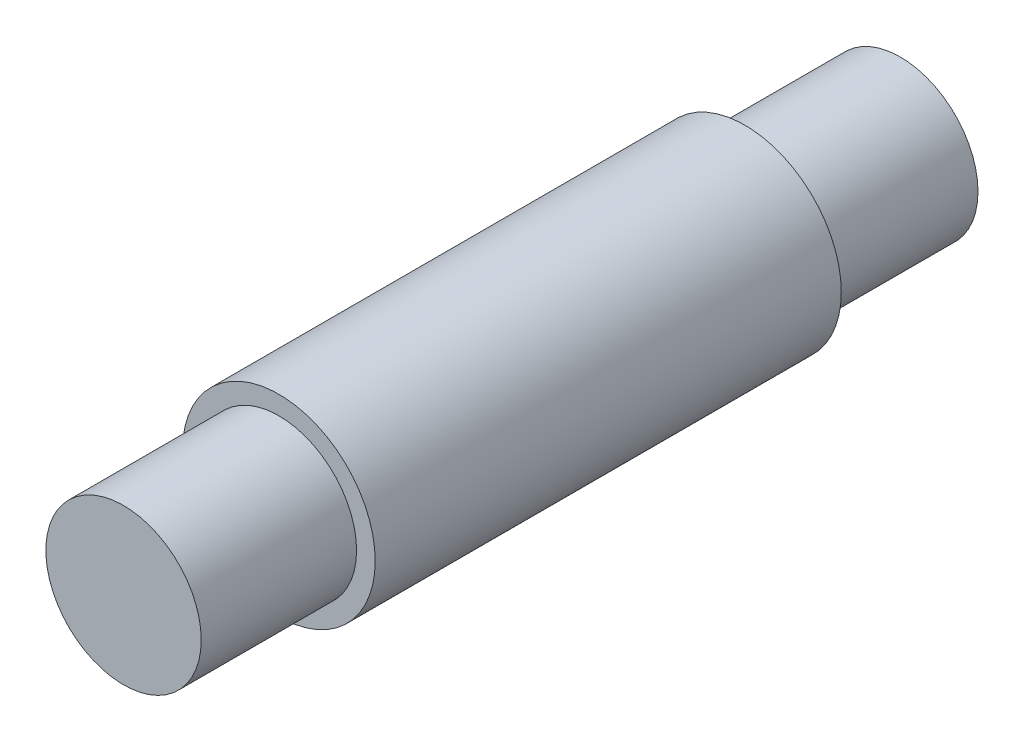
from build123d import *

# Parameters (mm, degrees)
SKETCH2_R           = 1.55
BOSS_EXTRUDE2_DEPTH = 3.75
SKETCH4_R           = 1.25
BOSS_EXTRUDE3_DEPTH = 2.5


with BuildPart() as part:
    # Sketch2 → Boss-Extrude2 (new body)
    with BuildSketch(Plane.XY):
        Circle(SKETCH2_R)
    boss_extrude2 = extrude(amount=BOSS_EXTRUDE2_DEPTH)

    # Sketch4 → Boss-Extrude3 (add)
    with BuildSketch(Plane.XY.offset(3.75)):
        Circle(SKETCH4_R)
    boss_extrude3 = extrude(amount=BOSS_EXTRUDE3_DEPTH)

    # Mirror3: Boss-Extrude2, Boss-Extrude3 across plane
    add(boss_extrude2.mirror(Plane.XY))
    add(boss_extrude3.mirror(Plane.XY))


solid = part.part
